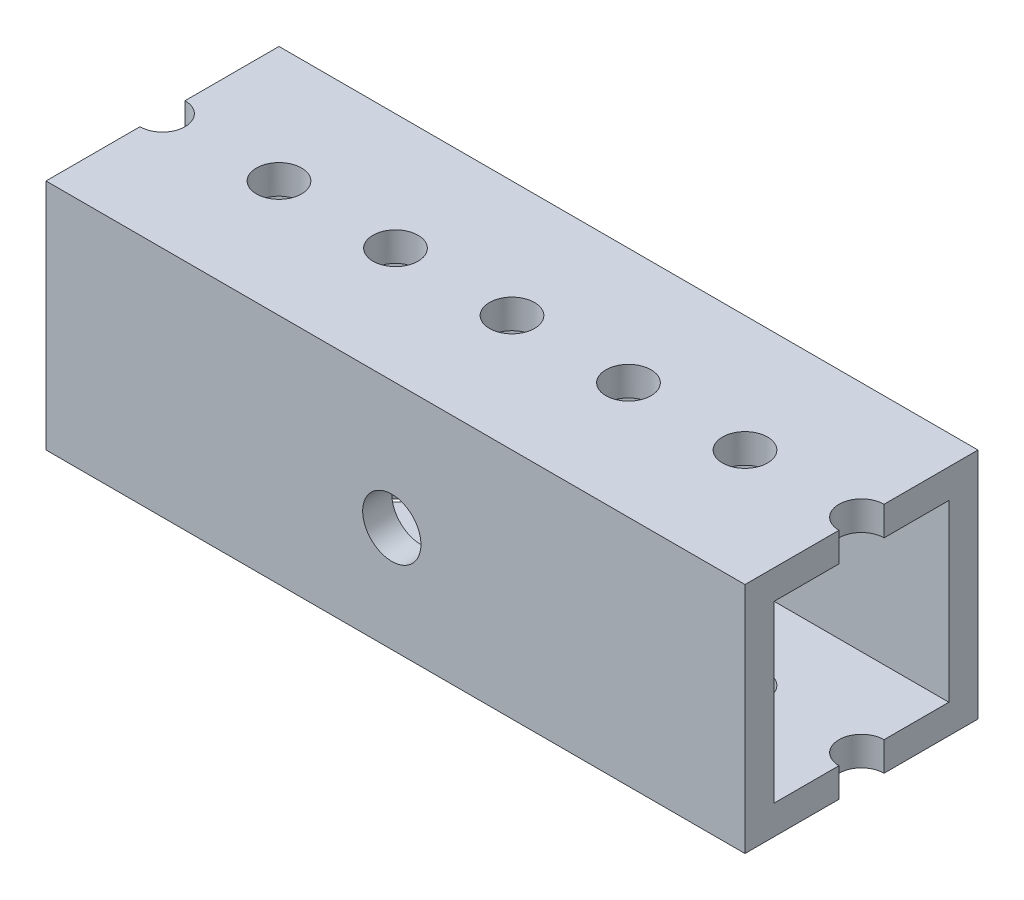
from build123d import *

# Parameters (mm, degrees)
SKETCH1_W                   = 25.4
SKETCH1_H                   = 25.4
SKETCH1_W_2                 = 19.05
SKETCH1_H_2                 = 19.05
BASE_TUBE_DEPTH             = 38.1
INITIAL_10_HOLE_D           = 4.9149
F_10_HOLE_PATTERN_COUNT     = 4
F_10_HOLE_PATTERN_PITCH     = 12.7
F_10_HOLE_PATTERN_COL_COUNT = 4
F_10_HOLE_PATTERN_COL_PITCH = 12.7
CUT_EXTRUDE1_REACH          = 49.519
SKETCH8_R                   = 3.175


with BuildPart() as part:
    # Sketch1 → Base Tube (new, symmetric)
    with BuildSketch(Plane(origin=(0, 0, 0), x_dir=(0, 0, -1), z_dir=(1, 0, 0))):
        Rectangle(SKETCH1_W, SKETCH1_H)
        Rectangle(SKETCH1_W_2, SKETCH1_H_2, mode=Mode.SUBTRACT)
    extrude(amount=BASE_TUBE_DEPTH, both=True)

    # Initial #10 Hole (through all)
    with Locations(Plane(origin=(0, 12.7, 0), x_dir=(1, 0, 0), z_dir=(0, 1, 0))):
        with Locations((0, 0)):
            initial_10_hole = Hole(INITIAL_10_HOLE_D / 2)

    # #10 Hole Pattern: Initial #10 Hole ×4
    with Locations(*[(i * F_10_HOLE_PATTERN_PITCH, 0, 0) for i in range(1, F_10_HOLE_PATTERN_COUNT)]):
        add(initial_10_hole, mode=Mode.SUBTRACT)

    # #10 Hole Pattern col: Initial #10 Hole ×4
    with Locations(*[(-i * F_10_HOLE_PATTERN_COL_PITCH, 0, 0) for i in range(1, F_10_HOLE_PATTERN_COL_COUNT)]):
        add(initial_10_hole, mode=Mode.SUBTRACT)

    # Sketch8 → Cut-Extrude1 (cut, up to next)
    with BuildSketch(Plane.XY.offset(12.7), mode=Mode.PRIVATE) as cut_extrude1_sk1:
        with Locations((-0.402530278, -1.19507)):
            Circle(SKETCH8_R)
    cut_extrude1_tool1 = extrude(cut_extrude1_sk1.sketch, amount=-CUT_EXTRUDE1_REACH, mode=Mode.PRIVATE) & part.part
    add(cut_extrude1_tool1.solids().sort_by_distance((-0.40253, -1.19507, 12.7))[0], mode=Mode.SUBTRACT)


solid = part.part
